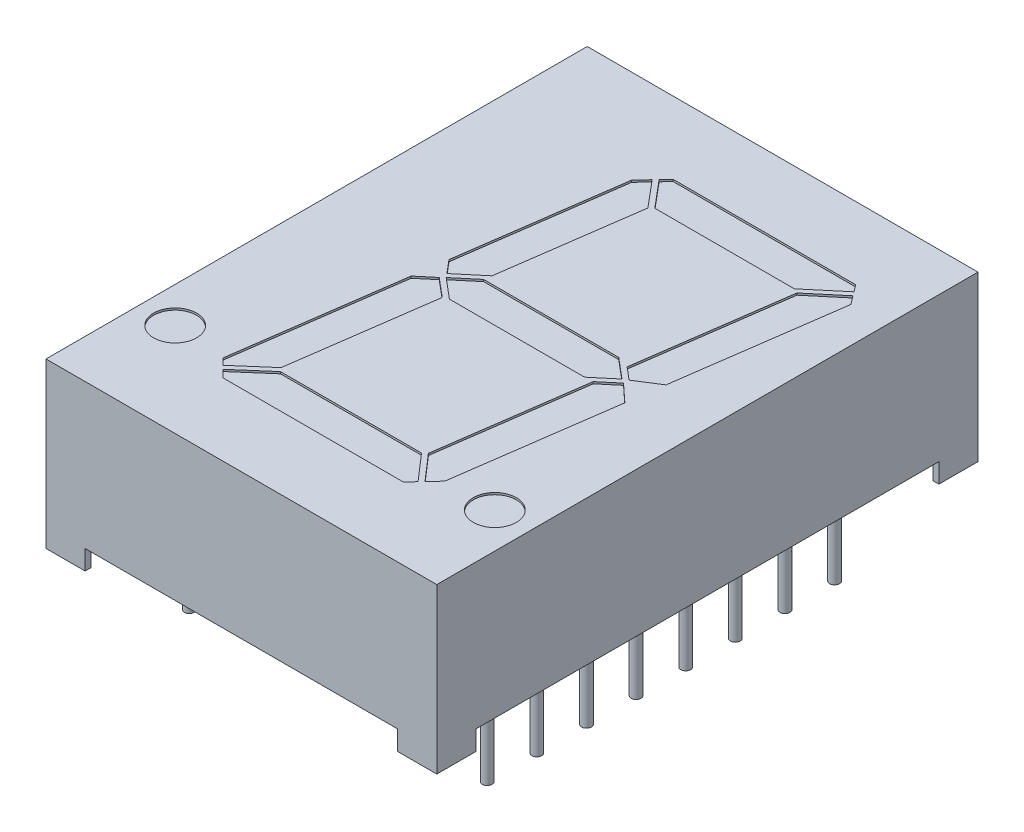
from build123d import *

# Parameters (mm, degrees)
SKETCH1_W          = 20
SKETCH1_H          = 27.7
EXTRUDE2_DEPTH     = 8.4
SKETCH2_W          = 8
SKETCH2_H          = 1
CUT_EXTRUDE2_DEPTH = 31.624336728
SKETCH3_W          = 23.7
SKETCH3_H          = 1
CUT_EXTRUDE3_DEPTH = 26.736792729
SKETCH6_R          = 1.1
CUT_EXTRUDE4_DEPTH = 0.1
SKETCH7_W          = 1.7
SKETCH7_H          = 1.7
CUT_EXTRUDE6_DEPTH = 1
SKETCH7_3_R        = 0.25
EXTRUDE3_DEPTH     = 1
SKETCH7_4_R        = 0.25
SKETCH7_4_W        = 1.7
SKETCH7_4_H        = 1.7
EXTRUDE4_DEPTH     = 4
CUT_EXTRUDE7_DEPTH = 0.01


with BuildPart() as part:
    # Sketch1 → Extrude2 (new body)
    with BuildSketch(Plane(origin=(0, 0, 0), x_dir=(1, 0, 0), z_dir=(0, 1, 0))):
        Rectangle(SKETCH1_W, SKETCH1_H)
    extrude(amount=-EXTRUDE2_DEPTH)

    # Sketch2 → Cut-Extrude2 (cut, through all)
    with BuildSketch(Plane.XY.offset(13.85)):
        with Locations((-4, -7.9)):
            Rectangle(SKETCH2_W, SKETCH2_H)
        with Locations((4, -7.9)):
            Rectangle(SKETCH2_W, SKETCH2_H)
    extrude(amount=-CUT_EXTRUDE2_DEPTH, mode=Mode.SUBTRACT)

    # Sketch3 → Cut-Extrude3 (cut, through all)
    with BuildSketch(Plane(origin=(10, 0, 0), x_dir=(0, 0, -1), z_dir=(1, 0, 0))):
        with Locations((0, -7.9)):
            Rectangle(SKETCH3_W, SKETCH3_H)
    extrude(amount=-CUT_EXTRUDE3_DEPTH, mode=Mode.SUBTRACT)

    # Sketch6 → Cut-Extrude4 (cut)
    with BuildSketch(Plane(origin=(0, 0, 0), x_dir=(-1, 0, 0), z_dir=(0, 1, 0))):
        Polygon((2.433435176, -9.60730171), (2.941033223, -9.062969448), (4.092747259, -0.868098261), (3.527367456, -0.194304848), (2.272228803, -1.247491229), (1.289013327, -8.243432859), align=None)
        Polygon((1.918035682, -10.16), (2.261655164, -9.79151322), (1.102427931, -8.41), (-6.041213399, -8.41), (-7.699102553, -9.801134178), (-7.428677759, -10.16), align=None)
        Polygon((3.550142222, 0.17519455), (4.331518452, 0.830847056), (5.518423673, 9.276116524), (5.191950187, 9.602590009), (3.602983803, 8.221322605), (2.585886741, 0.984300968), align=None)
        Polygon((-4.587215606, -0.875), (2.327215606, -0.875), (3.37, 0), (2.327215606, 0.875), (-4.587215606, 0.875), (-5.63, 0), align=None)
        Polygon((-8.180946538, -9.161705612), (-7.849762784, -9.601201299), (-6.291786749, -8.293904183), (-5.220331571, -0.67010445), (-5.860099282, -0.1332756), (-7.015053014, -0.865942131), align=None)
        Polygon((3.438969046, 8.41), (5.014741821, 9.779798375), (4.634540196, 10.16), (-4.596637953, 10.16), (-4.960572752, 9.769727709), (-3.778579488, 8.41), align=None)
        Polygon((-5.849760234, 0.141951091), (-5.006795684, 0.849282334), (-3.967256883, 8.245985243), (-5.132011502, 9.585882158), (-5.619635493, 9.062969448), (-6.755583867, 0.980276783), align=None)
        with Locations(Location((-8.180946538, 9.06, 0), (0, 0, 90))):
            Circle(SKETCH6_R)
        with Locations(Location((8.180946538, 9.06, 0), (0, 0, 90))):
            Circle(SKETCH6_R)
    extrude(amount=-CUT_EXTRUDE4_DEPTH, mode=Mode.SUBTRACT)

    # Sketch7 → Cut-Extrude6 (cut)
    with BuildSketch(Plane.XZ.offset(8.4)):
        with Locations((-8.85, 12.7)):
            Rectangle(SKETCH7_W, SKETCH7_H)
        with Locations((-8.85, -12.7)):
            Rectangle(SKETCH7_W, SKETCH7_H)
        with Locations((8.85, -12.7)):
            Rectangle(SKETCH7_W, SKETCH7_H)
        with Locations((8.85, 12.7)):
            Rectangle(SKETCH7_W, SKETCH7_H)
    extrude(amount=-CUT_EXTRUDE6_DEPTH, mode=Mode.SUBTRACT)

    # Sketch7_3 → Extrude3 (add)
    with BuildSketch(Plane.XZ.offset(8.4)):
        with Locations((-7.62, 8.89)):
            Circle(SKETCH7_3_R)
        with Locations((-7.62, 6.35)):
            Circle(SKETCH7_3_R)
        with Locations((-7.62, -8.89)):
            Circle(SKETCH7_3_R)
        with Locations((-7.62, 3.81)):
            Circle(SKETCH7_3_R)
        with Locations((-7.62, 1.27)):
            Circle(SKETCH7_3_R)
        with Locations((-7.62, -1.27)):
            Circle(SKETCH7_3_R)
        with Locations((-7.62, -3.81)):
            Circle(SKETCH7_3_R)
        with Locations((-7.62, -6.35)):
            Circle(SKETCH7_3_R)
        with Locations(Location((7.62, -6.35, 0), (0, 0, 180))):
            Circle(SKETCH7_3_R)
        with Locations(Location((7.62, -3.81, 0), (0, 0, 180))):
            Circle(SKETCH7_3_R)
        with Locations(Location((7.62, -1.27, 0), (0, 0, 180))):
            Circle(SKETCH7_3_R)
        with Locations(Location((7.62, 1.27, 0), (0, 0, 180))):
            Circle(SKETCH7_3_R)
        with Locations(Location((7.62, 3.81, 0), (0, 0, 180))):
            Circle(SKETCH7_3_R)
        with Locations(Location((7.62, -8.89, 0), (0, 0, 180))):
            Circle(SKETCH7_3_R)
        with Locations(Location((7.62, 6.35, 0), (0, 0, 180))):
            Circle(SKETCH7_3_R)
        with Locations(Location((7.62, 8.89, 0), (0, 0, 180))):
            Circle(SKETCH7_3_R)
    extrude(amount=-EXTRUDE3_DEPTH)


with BuildPart() as extrude4_tool:
    # Sketch7_4 → Extrude4 (new body)
    with BuildSketch(Plane.XZ.offset(8.4)):
        with Locations((-7.62, 8.89)):
            Circle(SKETCH7_4_R)
        with Locations((-7.62, 6.35)):
            Circle(SKETCH7_4_R)
        with Locations((-7.62, -8.89)):
            Circle(SKETCH7_4_R)
        with Locations((-7.62, 3.81)):
            Circle(SKETCH7_4_R)
        with Locations((-7.62, 1.27)):
            Circle(SKETCH7_4_R)
        with Locations((-7.62, -1.27)):
            Circle(SKETCH7_4_R)
        with Locations((-7.62, -3.81)):
            Circle(SKETCH7_4_R)
        with Locations((-7.62, -6.35)):
            Circle(SKETCH7_4_R)
        with Locations(Location((7.62, -6.35, 0), (0, 0, 180))):
            Circle(SKETCH7_4_R)
        with Locations(Location((7.62, -3.81, 0), (0, 0, 180))):
            Circle(SKETCH7_4_R)
        with Locations(Location((7.62, -1.27, 0), (0, 0, 180))):
            Circle(SKETCH7_4_R)
        with Locations(Location((7.62, 1.27, 0), (0, 0, 180))):
            Circle(SKETCH7_4_R)
        with Locations(Location((7.62, 3.81, 0), (0, 0, 180))):
            Circle(SKETCH7_4_R)
        with Locations(Location((7.62, -8.89, 0), (0, 0, 180))):
            Circle(SKETCH7_4_R)
        with Locations(Location((7.62, 6.35, 0), (0, 0, 180))):
            Circle(SKETCH7_4_R)
        with Locations(Location((7.62, 8.89, 0), (0, 0, 180))):
            Circle(SKETCH7_4_R)
        with Locations((-8.85, 12.7)):
            Rectangle(SKETCH7_4_W, SKETCH7_4_H)
        with Locations((-8.85, -12.7)):
            Rectangle(SKETCH7_4_W, SKETCH7_4_H)
        with Locations((8.85, -12.7)):
            Rectangle(SKETCH7_4_W, SKETCH7_4_H)
        with Locations((8.85, 12.7)):
            Rectangle(SKETCH7_4_W, SKETCH7_4_H)
    extrude(amount=EXTRUDE4_DEPTH)


with BuildPart() as part_1:
    add(part.part)


with BuildPart() as part_2:
    # Extrude4: joined with extrude4_tool
    add(part_1.part.fuse(extrude4_tool.part, tol=0.00001))


with BuildPart() as extrude4_kept_piece:
    # of the separate pieces the step leaves, the one the design keeps (extrude4_pieces_kept)
    add(part_2.part.solids().sort_by_distance((-10, 0, -13.85))[0])

    # Sketch8 → Cut-Extrude7 (cut)
    with BuildSketch(Plane.XZ.offset(7.4)):
        Polygon((0.650981301, 11.095437234), (0.641345884, 11.095437234), (0.619571044, 11.148001337), (0.595712871, 11.095437234), (0.594190435, 11.095437234), (0.570853096, 11.148001337), (0.548877935, 11.095437234), (0.539442839, 11.095437234), (0.569991717, 11.168514157), (0.571854698, 11.168514157), (0.59521207, 11.115950055), (0.619050211, 11.168514157), (0.620712871, 11.168514157), align=None)
        Polygon((0.535596685, 11.095437234), (0.525961269, 11.095437234), (0.504186429, 11.148001337), (0.480328256, 11.095437234), (0.47880582, 11.095437234), (0.45546848, 11.148001337), (0.43349332, 11.095437234), (0.424058224, 11.095437234), (0.454607102, 11.168514157), (0.456470083, 11.168514157), (0.479827455, 11.115950055), (0.503665596, 11.168514157), (0.505328256, 11.168514157), align=None)
        Polygon((0.42021207, 11.095437234), (0.410576653, 11.095437234), (0.388801814, 11.148001337), (0.364943641, 11.095437234), (0.363421205, 11.095437234), (0.340083865, 11.148001337), (0.318108705, 11.095437234), (0.308673609, 11.095437234), (0.339222487, 11.168514157), (0.341085467, 11.168514157), (0.364442839, 11.115950055), (0.38828098, 11.168514157), (0.389943641, 11.168514157), align=None)
        with BuildLine():
            add(Edge.make_bspline(
                [(0.28495566, 11.153129542), (0.284398411, 11.153161539), (0.283312413, 11.153223897), (0.281739855, 11.153682194), (0.28030282, 11.154455474), (0.279030697, 11.155517968), (0.2779734, 11.156786442), (0.277191223, 11.158219826), (0.276711918, 11.159796943), (0.276652672, 11.160898607), (0.276622326, 11.161462875)],
                knots=[0, 0, 0, 0, 1.020591893, 1.988988293, 2.974634352, 3.991697318, 5.008760285, 5.983632262, 6.967224335, 8, 8, 8, 8], degree=3))
            add(Edge.make_bspline(
                [(0.276622326, 11.161462875), (0.276653779, 11.16201367), (0.276715909, 11.163101704), (0.277191448, 11.164665515), (0.277972409, 11.166100527), (0.279037392, 11.167365999), (0.280295133, 11.168454064), (0.28174441, 11.169216615), (0.283308358, 11.169708497), (0.28439768, 11.169766499), (0.28495566, 11.169796209)],
                knots=[0, 0, 0, 0, 1.010056097, 1.99525427, 2.971718109, 3.990441831, 5.01702829, 6.004283803, 6.977741589, 8, 8, 8, 8], degree=3))
            add(Edge.make_bspline(
                [(0.28495566, 11.169796209), (0.285513238, 11.16976538), (0.286608179, 11.169704839), (0.28817798, 11.169226394), (0.289618477, 11.168446624), (0.290876545, 11.167367962), (0.291932968, 11.166093937), (0.292750185, 11.164675286), (0.293187783, 11.163097181), (0.293254938, 11.162012779), (0.293288993, 11.161462875)],
                knots=[0, 0, 0, 0, 1.021821805, 2.006599202, 2.982645994, 4.008793999, 5.027082625, 6.009034913, 6.990375297, 8, 8, 8, 8], degree=3))
            add(Edge.make_bspline(
                [(0.293288993, 11.161462875), (0.293255953, 11.16089953), (0.293191555, 11.159801539), (0.292750384, 11.158210065), (0.291931974, 11.156793039), (0.290883218, 11.15551602), (0.289610868, 11.154462798), (0.288182449, 11.15367255), (0.286604188, 11.153227503), (0.285512523, 11.153162633), (0.28495566, 11.153129542)],
                knots=[0, 0, 0, 0, 1.032329927, 2.012066096, 2.992413168, 4.009037178, 5.025661188, 6.000112418, 6.979848586, 8, 8, 8, 8], degree=3))
        make_face()
        with BuildLine():
            Line((0.263801814, 11.149223292), (0.255348288, 11.144155183))
            add(Edge.make_bspline(
                [(0.255348288, 11.144155183), (0.254562053, 11.145471308), (0.253055656, 11.147992954), (0.25054276, 11.151400326), (0.247938963, 11.154296388), (0.245224982, 11.156664291), (0.242417383, 11.158528545), (0.239497839, 11.159848609), (0.236476187, 11.160671922), (0.234419792, 11.160771925), (0.23339316, 11.16082185)],
                knots=[0, 0, 0, 0, 1.272034388, 2.437168799, 3.508375237, 4.49857839, 5.41946034, 6.295179144, 7.148887113, 8, 8, 8, 8], degree=3))
            add(Edge.make_bspline(
                [(0.23339316, 11.16082185), (0.23251657, 11.16079685), (0.230778728, 11.160747287), (0.228215332, 11.160290292), (0.225738213, 11.159542652), (0.223372023, 11.158529136), (0.221179343, 11.157283336), (0.21922604, 11.155814196), (0.217575635, 11.154117037), (0.216211197, 11.152253051), (0.215143093, 11.150261148), (0.214383111, 11.148190381), (0.213894915, 11.146053948), (0.213833019, 11.144605157), (0.213801814, 11.143874734)],
                knots=[0, 0, 0, 0, 1.095645842, 2.172120455, 3.244862764, 4.326153987, 5.384857088, 6.392105572, 7.372507978, 8.334705661, 9.272564127, 10.189475455, 11.087205874, 12, 12, 12, 12], degree=3))
            add(Edge.make_bspline(
                [(0.213801814, 11.143874734), (0.213843032, 11.143041861), (0.213926504, 11.141355201), (0.214662147, 11.138862475), (0.215785443, 11.136384982), (0.216841215, 11.134852204), (0.217387551, 11.134059029)],
                knots=[0, 0, 0, 0, 0.938992559, 1.901562324, 2.914110574, 4, 4, 4, 4], degree=3))
            add(Edge.make_bspline(
                [(0.217387551, 11.134059029), (0.217833949, 11.133485019), (0.218773858, 11.13227642), (0.220413494, 11.130508971), (0.222277864, 11.128637569), (0.224415236, 11.126699567), (0.226794444, 11.12465532), (0.22944246, 11.122542743), (0.232328366, 11.120330327), (0.234363879, 11.11886909), (0.235416397, 11.118113516)],
                knots=[0, 0, 0, 0, 0.722283655, 1.520795216, 2.39349503, 3.346893347, 4.386874146, 5.510198126, 6.712579003, 8, 8, 8, 8], degree=3))
            add(Edge.make_bspline(
                [(0.235416397, 11.118113516), (0.236468371, 11.117363957), (0.238479665, 11.115930856), (0.241294581, 11.113806665), (0.243808362, 11.111852175), (0.246033814, 11.110094611), (0.247913365, 11.108457316), (0.249515723, 11.107028042), (0.250781773, 11.105730465), (0.2514863, 11.10488938), (0.251802615, 11.104511754)],
                knots=[0, 0, 0, 0, 1.452255772, 2.776602448, 3.96446981, 5.032613149, 5.964194703, 6.766668629, 7.446264616, 8, 8, 8, 8], degree=3))
            add(Edge.make_bspline(
                [(0.251802615, 11.104511754), (0.252244614, 11.103923123), (0.253113863, 11.102765503), (0.254262519, 11.100956638), (0.255231184, 11.099108492), (0.256010778, 11.097214369), (0.256641206, 11.095288503), (0.257079515, 11.093316435), (0.25734968, 11.091311554), (0.257377587, 11.089962644), (0.257391557, 11.089287395)],
                knots=[0, 0, 0, 0, 1.068019517, 2.100403715, 3.106014851, 4.09224787, 5.069873182, 6.043214339, 7.020455327, 8, 8, 8, 8], degree=3))
            add(Edge.make_bspline(
                [(0.257391557, 11.089287395), (0.25735443, 11.08822931), (0.257280969, 11.086135758), (0.25665457, 11.083079049), (0.255677556, 11.080151662), (0.254264041, 11.07741875), (0.252518086, 11.074884187), (0.250445634, 11.072592933), (0.248007873, 11.070623856), (0.245294023, 11.068949984), (0.242358197, 11.067614607), (0.239272816, 11.066641568), (0.236051743, 11.066071308), (0.233862811, 11.06599087), (0.232752134, 11.065950055)],
                knots=[0, 0, 0, 0, 1.005367131, 1.989245246, 2.955191616, 3.932180104, 4.904534562, 5.875498653, 6.859376768, 7.874484044, 8.900379497, 9.918679785, 10.943926428, 12, 12, 12, 12], degree=3))
            add(Edge.make_bspline(
                [(0.232752134, 11.065950055), (0.231573367, 11.065989389), (0.229235731, 11.066067394), (0.225796173, 11.066787337), (0.222464806, 11.06790594), (0.219794977, 11.069238175), (0.217704674, 11.070554422), (0.216112269, 11.071756352), (0.214489799, 11.073137078), (0.212854745, 11.07472585), (0.211190951, 11.076490849), (0.209506086, 11.078447029), (0.207784382, 11.080576757), (0.206677134, 11.082097522), (0.206109506, 11.082877138)],
                knots=[0, 0, 0, 0, 1.286534051, 2.551350862, 3.822568981, 5.117864672, 5.799956111, 6.519305446, 7.295594771, 8.126302591, 9.008831062, 9.944975596, 10.946496709, 12, 12, 12, 12], degree=3))
            Line((0.206109506, 11.082877138), (0.214222487, 11.089026978))
            add(Edge.make_bspline(
                [(0.214222487, 11.089026978), (0.214712335, 11.088395836), (0.215655668, 11.087180404), (0.217088414, 11.085478853), (0.218436765, 11.083922449), (0.219775384, 11.08257415), (0.221001086, 11.081332974), (0.222211843, 11.080289222), (0.223360882, 11.079409756), (0.224805926, 11.078469972), (0.226641137, 11.077560724), (0.228923394, 11.076778987), (0.231309992, 11.076298563), (0.232930201, 11.076237502), (0.233753737, 11.076206465)],
                knots=[0, 0, 0, 0, 1.181426797, 2.275151783, 3.28963443, 4.225459815, 5.084396437, 5.868484344, 6.587427557, 7.222918358, 8.415355282, 9.605213164, 10.782753814, 12, 12, 12, 12], degree=3))
            add(Edge.make_bspline(
                [(0.233753737, 11.076206465), (0.234787024, 11.076240518), (0.236779621, 11.076306186), (0.239601935, 11.077042254), (0.242156834, 11.078161396), (0.244346784, 11.079775186), (0.246154992, 11.081699135), (0.247479212, 11.083893264), (0.248270939, 11.086316593), (0.248367846, 11.088006221), (0.248417198, 11.088866722)],
                knots=[0, 0, 0, 0, 1.144248881, 2.206576175, 3.214949548, 4.222996039, 5.203671638, 6.127710127, 7.046472867, 8, 8, 8, 8], degree=3))
            add(Edge.make_bspline(
                [(0.248417198, 11.088866722), (0.248404794, 11.089402214), (0.248379812, 11.09048066), (0.248081965, 11.092070714), (0.247637491, 11.09364205), (0.247007461, 11.09520372), (0.246151243, 11.096800215), (0.244988349, 11.098422436), (0.243533142, 11.100110982), (0.242416308, 11.101208132), (0.241826653, 11.101787395)],
                knots=[0, 0, 0, 0, 0.858500039, 1.728959331, 2.587258638, 3.476905708, 4.426389682, 5.487945037, 6.673710648, 8, 8, 8, 8], degree=3))
            add(Edge.make_bspline(
                [(0.241826653, 11.101787395), (0.241607757, 11.101982738), (0.241087709, 11.10244683), (0.240136969, 11.103206609), (0.23888146, 11.104143831), (0.237353969, 11.105303469), (0.23552633, 11.106648654), (0.233398342, 11.108162185), (0.230993727, 11.109893199), (0.229287387, 11.111103414), (0.228385147, 11.111743324)],
                knots=[0, 0, 0, 0, 0.420754252, 0.999615792, 1.744751191, 2.668019286, 3.750313428, 4.999500688, 6.413464383, 8, 8, 8, 8], degree=3))
            add(Edge.make_bspline(
                [(0.228385147, 11.111743324), (0.227299836, 11.112533078), (0.225198282, 11.114062326), (0.222208055, 11.11635991), (0.219496838, 11.118607015), (0.217054913, 11.120789145), (0.214858827, 11.122890237), (0.212930717, 11.124933939), (0.211261835, 11.126906849), (0.209440628, 11.129419042), (0.207601749, 11.132532997), (0.206025061, 11.136349899), (0.205021999, 11.140177755), (0.204891729, 11.142747209), (0.204827455, 11.144014959)],
                knots=[0, 0, 0, 0, 1.163604038, 2.253157948, 3.268574773, 4.215621239, 5.091738613, 5.902582348, 6.650434646, 7.330118262, 8.591011492, 9.77460283, 10.902005569, 12, 12, 12, 12], degree=3))
            add(Edge.make_bspline(
                [(0.204827455, 11.144014959), (0.20484626, 11.144911467), (0.204883504, 11.146687074), (0.205310529, 11.149294602), (0.205938405, 11.151826017), (0.206874178, 11.154249815), (0.208043921, 11.156593009), (0.209468074, 11.158851492), (0.211193986, 11.160988154), (0.213111267, 11.16304449), (0.21524088, 11.164904242), (0.217494447, 11.166560694), (0.219859316, 11.167978985), (0.222362496, 11.169093226), (0.224962752, 11.169984523), (0.22767229, 11.170623382), (0.230496931, 11.171016812), (0.232416973, 11.171057549), (0.23339316, 11.17107826)],
                knots=[0, 0, 0, 0, 0.98378539, 1.948466333, 2.894822735, 3.844243623, 4.795447569, 5.768042124, 6.770299647, 7.807997672, 8.852593179, 9.870666288, 10.876941106, 11.874841786, 12.874492863, 13.892063892, 14.928283473, 16, 16, 16, 16], degree=3))
            add(Edge.make_bspline(
                [(0.23339316, 11.17107826), (0.234148422, 11.171063487), (0.235649435, 11.171034128), (0.237863655, 11.170780725), (0.240037215, 11.170409105), (0.242142824, 11.16984252), (0.244206698, 11.169138909), (0.24621045, 11.168277447), (0.248158913, 11.167251895), (0.250054495, 11.166060668), (0.251914544, 11.164687462), (0.253731555, 11.163101952), (0.255514623, 11.161311726), (0.257271155, 11.159319276), (0.258959773, 11.157091667), (0.260622941, 11.154664228), (0.262251999, 11.152029115), (0.26327556, 11.150176035), (0.263801814, 11.149223292)],
                knots=[0, 0, 0, 0, 0.915366252, 1.81920441, 2.69897508, 3.586533125, 4.459536084, 5.340758185, 6.227946952, 7.126403341, 8.052553006, 9.028121456, 10.047063623, 11.114014537, 12.24582441, 13.433687931, 14.680555077, 16, 16, 16, 16], degree=3))
        make_face()
        with BuildLine():
            Line((0.188160788, 11.095437234), (0.179186429, 11.095437234))
            Line((0.179186429, 11.095437234), (0.179186429, 11.129331465))
            add(Edge.make_bspline(
                [(0.179186429, 11.129331465), (0.179182375, 11.130326401), (0.179174619, 11.132229666), (0.17912202, 11.134968386), (0.178998303, 11.137466006), (0.178843623, 11.13972397), (0.178644705, 11.141741896), (0.178408037, 11.143512734), (0.178143511, 11.145056568), (0.177884576, 11.145986378), (0.177764153, 11.146418805)],
                knots=[0, 0, 0, 0, 1.388932606, 2.656963016, 3.823490214, 4.879454478, 5.816252168, 6.653371382, 7.373723809, 8, 8, 8, 8], degree=3))
            add(Edge.make_bspline(
                [(0.177764153, 11.146418805), (0.177570968, 11.146962314), (0.177188613, 11.148038033), (0.176495103, 11.149592026), (0.175637082, 11.151031238), (0.174698484, 11.152411658), (0.173614682, 11.153690567), (0.172401524, 11.154876316), (0.171080542, 11.155982738), (0.169145565, 11.157317172), (0.166500427, 11.158729373), (0.16303538, 11.159964873), (0.15927145, 11.160692398), (0.156666947, 11.160777902), (0.155328256, 11.16082185)],
                knots=[0, 0, 0, 0, 0.725930277, 1.436768641, 2.137297926, 2.832005607, 3.535753883, 4.242956221, 4.964984144, 5.701683124, 7.198126434, 8.723945959, 10.316137162, 12, 12, 12, 12], degree=3))
            add(Edge.make_bspline(
                [(0.155328256, 11.16082185), (0.153989395, 11.160778066), (0.15140551, 11.160693567), (0.147680909, 11.159975857), (0.144269905, 11.158804972), (0.141212327, 11.157147629), (0.138527367, 11.155127112), (0.136290154, 11.152755257), (0.134444218, 11.150108177), (0.133638237, 11.148133191), (0.133232903, 11.147139959)],
                knots=[0, 0, 0, 0, 1.157091467, 2.233085092, 3.266839029, 4.264239195, 5.228693433, 6.160074799, 7.074690074, 8, 8, 8, 8], degree=3))
            add(Edge.make_bspline(
                [(0.133232903, 11.147139959), (0.13311298, 11.14674093), (0.132847857, 11.145858775), (0.132565043, 11.144362037), (0.132299734, 11.142578857), (0.132122855, 11.140490511), (0.131920982, 11.138115414), (0.131851275, 11.135441282), (0.131751729, 11.13248388), (0.131750942, 11.130413321), (0.131750532, 11.129331465)],
                knots=[0, 0, 0, 0, 0.557560243, 1.232629526, 2.036798082, 2.970922211, 4.03790722, 5.227863888, 6.551574656, 8, 8, 8, 8], degree=3))
            Line((0.131750532, 11.129331465), (0.131750532, 11.095437234))
            Line((0.131750532, 11.095437234), (0.122776173, 11.095437234))
            Line((0.122776173, 11.095437234), (0.122776173, 11.131014157))
            add(Edge.make_bspline(
                [(0.122776173, 11.131014157), (0.122788838, 11.132222927), (0.12281341, 11.134568105), (0.122970146, 11.137976314), (0.123242819, 11.141158659), (0.123646007, 11.144105397), (0.12413513, 11.146817233), (0.12475363, 11.149295022), (0.125496073, 11.151542208), (0.126333844, 11.15359158), (0.127321116, 11.155451478), (0.128378342, 11.157206854), (0.129567089, 11.158851922), (0.130863589, 11.160401733), (0.132305368, 11.161818676), (0.133817133, 11.163175403), (0.135472709, 11.164388213), (0.137216302, 11.16552171), (0.13909187, 11.166527611), (0.141083279, 11.167397989), (0.143188425, 11.1681542), (0.145410594, 11.168738561), (0.147748483, 11.169231566), (0.150199108, 11.169559702), (0.152767132, 11.169769213), (0.154513183, 11.169787059), (0.155408384, 11.169796209)],
                knots=[0, 0, 0, 0, 1.493120159, 2.896857355, 4.213387119, 5.437035652, 6.569467867, 7.615715674, 8.588612823, 9.490833737, 10.346735778, 11.186995163, 12.020221603, 12.851363391, 13.679553205, 14.515225522, 15.358192885, 16.211587453, 17.082499898, 17.983626775, 18.894104459, 19.842498226, 20.819547185, 21.843713668, 22.894470975, 24, 24, 24, 24], degree=3))
            add(Edge.make_bspline(
                [(0.155408384, 11.169796209), (0.156296861, 11.169786516), (0.1580428, 11.16976747), (0.160604768, 11.169563226), (0.163060683, 11.169226539), (0.165400413, 11.168742513), (0.167633389, 11.16814949), (0.169748769, 11.167403305), (0.171749226, 11.16652263), (0.173639063, 11.16552077), (0.17541201, 11.164392338), (0.177064083, 11.163150373), (0.178624733, 11.161827278), (0.180050639, 11.16037793), (0.18135226, 11.158813179), (0.182535238, 11.157140058), (0.183619807, 11.155377477), (0.18460129, 11.153489928), (0.185444491, 11.151416451), (0.186188924, 11.149122245), (0.1867978, 11.146582174), (0.187293299, 11.143798405), (0.187691912, 11.140784261), (0.187968659, 11.137522306), (0.188123397, 11.134020486), (0.188148055, 11.131601918), (0.188160788, 11.1303531)],
                knots=[0, 0, 0, 0, 1.083759936, 2.129689164, 3.133164553, 4.10615121, 5.04285688, 5.949793092, 6.839814394, 7.707177441, 8.556916231, 9.400895077, 10.227072161, 11.05083587, 11.877976332, 12.707560346, 13.548664154, 14.401248865, 15.299878211, 16.27626931, 17.341250723, 18.483766318, 19.724630785, 21.049282549, 22.476408703, 24, 24, 24, 24], degree=3))
            Line((0.188160788, 11.1303531), (0.188160788, 11.095437234))
        make_face()
        with BuildLine():
            Line((0.102263352, 11.095437234), (0.093288993, 11.095437234))
            Line((0.093288993, 11.095437234), (0.093288993, 11.108618324))
            add(Edge.make_bspline(
                [(0.093288993, 11.108618324), (0.092332429, 11.10742103), (0.090479099, 11.105101289), (0.087360909, 11.102076369), (0.084109565, 11.099537977), (0.08067226, 11.097539359), (0.077084363, 11.096027799), (0.073356057, 11.094937786), (0.069467161, 11.094283815), (0.06682245, 11.094198396), (0.065484506, 11.094155183)],
                knots=[0, 0, 0, 0, 1.127869841, 2.185233117, 3.191641716, 4.159226741, 5.10472073, 6.052603964, 7.014823782, 8, 8, 8, 8], degree=3))
            add(Edge.make_bspline(
                [(0.065484506, 11.094155183), (0.064131557, 11.094202229), (0.061482181, 11.094294355), (0.057638589, 11.095106108), (0.05402366, 11.096390713), (0.050685731, 11.098196161), (0.047676165, 11.100437741), (0.045066357, 11.103067132), (0.042871642, 11.106052655), (0.041406771, 11.108847175), (0.040459308, 11.111329424), (0.039836673, 11.113452557), (0.039332948, 11.115818945), (0.03888159, 11.118422736), (0.038580485, 11.121274388), (0.038341804, 11.124367097), (0.038171081, 11.127700325), (0.03816429, 11.130005653), (0.038160788, 11.131194446)],
                knots=[0, 0, 0, 0, 1.235764162, 2.419900973, 3.574701258, 4.732869372, 5.875730734, 6.993815468, 8.107424371, 9.251605764, 9.866123335, 10.534503958, 11.272175692, 12.077112099, 12.949509943, 13.89253218, 14.913238789, 16, 16, 16, 16], degree=3))
            Line((0.038160788, 11.131194446), (0.038160788, 11.168514157))
            Line((0.038160788, 11.168514157), (0.047135147, 11.168514157))
            Line((0.047135147, 11.168514157), (0.047135147, 11.134139157))
            add(Edge.make_bspline(
                [(0.047135147, 11.134139157), (0.047140644, 11.133144229), (0.04715116, 11.1312411), (0.047184761, 11.12851629), (0.047263855, 11.126051848), (0.047379567, 11.123840693), (0.047541534, 11.121890918), (0.047714922, 11.120192654), (0.047925217, 11.118760942), (0.048112743, 11.117899084), (0.048196846, 11.117512555)],
                knots=[0, 0, 0, 0, 1.430803381, 2.736883362, 3.918614142, 4.976458302, 5.92063272, 6.731858525, 7.431260095, 8, 8, 8, 8], degree=3))
            add(Edge.make_bspline(
                [(0.048196846, 11.117512555), (0.048498925, 11.116377134), (0.049078789, 11.114197613), (0.050540789, 11.111246318), (0.052344151, 11.10871328), (0.054578476, 11.106650597), (0.057183753, 11.10504485), (0.060164316, 11.103931554), (0.063489316, 11.103235018), (0.065828028, 11.103165681), (0.067047006, 11.103129542)],
                knots=[0, 0, 0, 0, 1.084232, 2.08126119, 3.027460722, 3.945137793, 4.874029258, 5.839697328, 6.874011781, 8, 8, 8, 8], degree=3))
            add(Edge.make_bspline(
                [(0.067047006, 11.103129542), (0.067769006, 11.103142941), (0.069197827, 11.103169458), (0.071315425, 11.103442423), (0.07337597, 11.103873536), (0.075373943, 11.104510319), (0.077313381, 11.105284558), (0.07920231, 11.106234586), (0.081014335, 11.107383726), (0.082774938, 11.10867536), (0.084411344, 11.110113757), (0.085955693, 11.11160959), (0.087312594, 11.113225493), (0.088544281, 11.114904333), (0.089606213, 11.116679834), (0.090533525, 11.118533018), (0.091320238, 11.120466816), (0.091711175, 11.121808958), (0.091906782, 11.122480504)],
                knots=[0, 0, 0, 0, 1.023939463, 2.026349741, 3.024227553, 4.007104963, 4.997624259, 5.984875705, 7.002218968, 8.038748769, 9.079772093, 10.091408226, 11.086177727, 12.069739863, 13.043026652, 14.017557731, 15.008077027, 16, 16, 16, 16], degree=3))
            add(Edge.make_bspline(
                [(0.091906782, 11.122480504), (0.092019343, 11.122973509), (0.092264383, 11.124046757), (0.092529046, 11.125808026), (0.092769262, 11.127845454), (0.092970318, 11.130156663), (0.09309333, 11.132749745), (0.093227455, 11.135613627), (0.093276286, 11.138759726), (0.093284639, 11.14095006), (0.093288993, 11.142091882)],
                knots=[0, 0, 0, 0, 0.615963638, 1.340920617, 2.168419149, 3.115676021, 4.16674242, 5.331190069, 6.6087489, 8, 8, 8, 8], degree=3))
            Line((0.093288993, 11.142091882), (0.093288993, 11.168514157))
            Line((0.093288993, 11.168514157), (0.102263352, 11.168514157))
            Line((0.102263352, 11.168514157), (0.102263352, 11.095437234))
        make_face()
        Polygon((0.015083865, 11.068514157), (0.006109506, 11.068514157), (0.006109506, 11.158257747), (-0.032352033, 11.158257747), (-0.032352033, 11.168514157), (0.015083865, 11.168514157), align=None)
        Polygon((-0.049018699, 11.068514157), (-0.105428956, 11.068514157), (-0.105428956, 11.078770568), (-0.057993058, 11.078770568), (-0.057993058, 11.109539798), (-0.105428956, 11.109539798), (-0.105428956, 11.119796209), (-0.057993058, 11.119796209), (-0.057993058, 11.158257747), (-0.105428956, 11.158257747), (-0.105428956, 11.168514157), (-0.049018699, 11.168514157), align=None)
        with BuildLine():
            Line((-0.123377674, 11.168514157), (-0.123377674, 11.068514157))
            Line((-0.123377674, 11.068514157), (-0.143569981, 11.068514157))
            add(Edge.make_bspline(
                [(-0.143569981, 11.068514157), (-0.145326242, 11.068526768), (-0.148719328, 11.068551131), (-0.153622492, 11.06870649), (-0.1581527, 11.068978544), (-0.16230738, 11.069382467), (-0.166093207, 11.069867288), (-0.169504117, 11.070483859), (-0.172545638, 11.071208989), (-0.174416189, 11.07182746), (-0.17530075, 11.072119927)],
                knots=[0, 0, 0, 0, 1.314317071, 2.539253741, 3.67075822, 4.709970291, 5.662644612, 6.526156501, 7.303037452, 8, 8, 8, 8], degree=3))
            add(Edge.make_bspline(
                [(-0.17530075, 11.072119927), (-0.176457846, 11.072560667), (-0.178745799, 11.073432154), (-0.182001644, 11.075078605), (-0.185077052, 11.076936479), (-0.187947742, 11.07904837), (-0.190620037, 11.08138729), (-0.193127562, 11.083934316), (-0.195398443, 11.086757444), (-0.197511004, 11.089769075), (-0.199360042, 11.092996613), (-0.200990538, 11.096375413), (-0.202382735, 11.099898919), (-0.203469022, 11.103592839), (-0.204366483, 11.107421695), (-0.204968657, 11.111414477), (-0.205368657, 11.115547906), (-0.205408659, 11.118352927), (-0.205428956, 11.119776177)],
                knots=[0, 0, 0, 0, 0.984696416, 1.947063185, 2.89840987, 3.841051395, 4.778753227, 5.721858861, 6.681155121, 7.65838316, 8.646299769, 9.637283673, 10.641736726, 11.657050558, 12.698485921, 13.768600492, 14.86780186, 16, 16, 16, 16], degree=3))
            add(Edge.make_bspline(
                [(-0.205428956, 11.119776177), (-0.205410973, 11.121012208), (-0.205375536, 11.123447936), (-0.205057729, 11.127037736), (-0.204594915, 11.130520762), (-0.203881666, 11.13388172), (-0.203005242, 11.137143238), (-0.201923512, 11.140289875), (-0.200641387, 11.143323767), (-0.199154487, 11.146220819), (-0.197526391, 11.148973985), (-0.195752314, 11.151539643), (-0.193892998, 11.153946082), (-0.19188063, 11.156138936), (-0.18978184, 11.158186491), (-0.187525242, 11.159997919), (-0.185181495, 11.161657315), (-0.182680185, 11.163114284), (-0.18000079, 11.164410301), (-0.17707332, 11.165504796), (-0.17390846, 11.16644669), (-0.170485239, 11.167197127), (-0.166815073, 11.167802017), (-0.162888014, 11.168204843), (-0.158711415, 11.168478009), (-0.155843426, 11.168501874), (-0.154367257, 11.168514157)],
                knots=[0, 0, 0, 0, 1.105894396, 2.179280415, 3.222964075, 4.248423888, 5.251546139, 6.243661943, 7.223682738, 8.196462441, 9.155694589, 10.083899862, 10.986397372, 11.874737962, 12.745335529, 13.607670254, 14.461432187, 15.313100333, 16.195087267, 17.121790994, 18.106827133, 19.14775296, 20.255889161, 21.433815148, 22.679170477, 24, 24, 24, 24], degree=3))
            Line((-0.154367257, 11.168514157), (-0.123377674, 11.168514157))
        make_face()
        with BuildLine():
            Line((-0.132352033, 11.158257747), (-0.143830398, 11.158257747))
            add(Edge.make_bspline(
                [(-0.143830398, 11.158257747), (-0.14547978, 11.158250659), (-0.148652146, 11.158237025), (-0.153213803, 11.158117391), (-0.157381785, 11.157921907), (-0.161156686, 11.157648333), (-0.164536372, 11.157286373), (-0.167527908, 11.156882804), (-0.170121487, 11.15638002), (-0.171690899, 11.155924278), (-0.172416135, 11.155713677)],
                knots=[0, 0, 0, 0, 1.375205317, 2.645023457, 3.804390687, 4.853969522, 5.800190428, 6.637939096, 7.370582563, 8, 8, 8, 8], degree=3))
            add(Edge.make_bspline(
                [(-0.172416135, 11.155713677), (-0.173328965, 11.155392228), (-0.175132821, 11.154757007), (-0.177729143, 11.15359787), (-0.180151807, 11.15222652), (-0.1824412, 11.150693161), (-0.18458261, 11.148974113), (-0.18656612, 11.147063912), (-0.188407398, 11.144984671), (-0.190076962, 11.142729384), (-0.19158695, 11.140323075), (-0.192891575, 11.137768425), (-0.193991359, 11.135079769), (-0.194893658, 11.132266461), (-0.195597143, 11.129326828), (-0.196092423, 11.126253491), (-0.196399343, 11.123047665), (-0.196435978, 11.120865281), (-0.196454597, 11.119756145)],
                knots=[0, 0, 0, 0, 0.998420628, 1.972994, 2.929372424, 3.86770908, 4.81360496, 5.759023883, 6.706048443, 7.676227424, 8.651287839, 9.634325482, 10.632389399, 11.645655052, 12.680158286, 13.74837235, 14.855672678, 16, 16, 16, 16], degree=3))
            add(Edge.make_bspline(
                [(-0.196454597, 11.119756145), (-0.196439916, 11.118586624), (-0.196411075, 11.116289089), (-0.196049173, 11.112917827), (-0.195519183, 11.109675883), (-0.194756833, 11.106560921), (-0.193771944, 11.103576996), (-0.192593443, 11.100707249), (-0.191162558, 11.09798861), (-0.189542645, 11.095398055), (-0.187723997, 11.092974816), (-0.185714679, 11.090747281), (-0.183535881, 11.088711302), (-0.181197642, 11.086863637), (-0.17866727, 11.085237144), (-0.175987585, 11.083790241), (-0.173120839, 11.082560867), (-0.171126153, 11.081907233), (-0.170112449, 11.081575055)],
                knots=[0, 0, 0, 0, 1.122272916, 2.204715076, 3.251197285, 4.274229216, 5.279697671, 6.265416158, 7.248880903, 8.225321784, 9.195852973, 10.153576302, 11.101466393, 12.055578741, 13.010401466, 13.985536859, 14.976245305, 16, 16, 16, 16], degree=3))
            add(Edge.make_bspline(
                [(-0.170112449, 11.081575055), (-0.169273845, 11.081343157), (-0.167490742, 11.080850078), (-0.164581043, 11.080312211), (-0.161306325, 11.079837796), (-0.157652048, 11.079436138), (-0.153622377, 11.079147929), (-0.149214215, 11.078931606), (-0.144425655, 11.078785702), (-0.141106154, 11.078775739), (-0.139383283, 11.078770568)],
                knots=[0, 0, 0, 0, 0.674548936, 1.434276114, 2.292660221, 3.240891867, 4.284742987, 5.42552168, 6.663806718, 8, 8, 8, 8], degree=3))
            Line((-0.139383283, 11.078770568), (-0.132352033, 11.078770568))
            Line((-0.132352033, 11.078770568), (-0.132352033, 11.158257747))
        make_face(mode=Mode.SUBTRACT)
        with BuildLine():
            add(Edge.make_bspline(
                [(-0.232993058, 11.153129542), (-0.233550307, 11.153161539), (-0.234636305, 11.153223897), (-0.236208863, 11.153682194), (-0.237645898, 11.154455474), (-0.23891802, 11.155517968), (-0.239975317, 11.156786442), (-0.240757495, 11.158219826), (-0.2412368, 11.159796943), (-0.241296046, 11.160898607), (-0.241326391, 11.161462875)],
                knots=[0, 0, 0, 0, 1.020591893, 1.988988293, 2.974634352, 3.991697318, 5.008760285, 5.983632262, 6.967224335, 8, 8, 8, 8], degree=3))
            add(Edge.make_bspline(
                [(-0.241326391, 11.161462875), (-0.241294939, 11.16201367), (-0.241232809, 11.163101704), (-0.24075727, 11.164665515), (-0.239976309, 11.166100527), (-0.238911326, 11.167365999), (-0.237653584, 11.168454064), (-0.236204308, 11.169216615), (-0.234640359, 11.169708497), (-0.233551038, 11.169766499), (-0.232993058, 11.169796209)],
                knots=[0, 0, 0, 0, 1.010056097, 1.99525427, 2.971718109, 3.990441831, 5.01702829, 6.004283803, 6.977741589, 8, 8, 8, 8], degree=3))
            add(Edge.make_bspline(
                [(-0.232993058, 11.169796209), (-0.23243548, 11.16976538), (-0.231340539, 11.169704839), (-0.229770738, 11.169226394), (-0.228330241, 11.168446624), (-0.227072173, 11.167367962), (-0.22601575, 11.166093937), (-0.225198533, 11.164675286), (-0.224760935, 11.163097181), (-0.22469378, 11.162012779), (-0.224659725, 11.161462875)],
                knots=[0, 0, 0, 0, 1.021821805, 2.006599202, 2.982645994, 4.008793999, 5.027082625, 6.009034913, 6.990375297, 8, 8, 8, 8], degree=3))
            add(Edge.make_bspline(
                [(-0.224659725, 11.161462875), (-0.224692765, 11.16089953), (-0.224757163, 11.159801539), (-0.225198334, 11.158210065), (-0.226016744, 11.156793039), (-0.2270655, 11.15551602), (-0.22833785, 11.154462798), (-0.229766269, 11.15367255), (-0.23134453, 11.153227503), (-0.232436195, 11.153162633), (-0.232993058, 11.153129542)],
                knots=[0, 0, 0, 0, 1.032329927, 2.012066096, 2.992413168, 4.009037178, 5.025661188, 6.000112418, 6.979848586, 8, 8, 8, 8], degree=3))
        make_face()
        with BuildLine():
            Line((-0.333634084, 11.111282587), (-0.326122065, 11.115950055))
            add(Edge.make_bspline(
                [(-0.326122065, 11.115950055), (-0.3252984, 11.1149263), (-0.323677156, 11.112911212), (-0.320861093, 11.110312166), (-0.317858496, 11.108070792), (-0.314612751, 11.106268632), (-0.311152296, 11.104846012), (-0.307470003, 11.10385731), (-0.303567006, 11.103235855), (-0.300890775, 11.10316556), (-0.2995195, 11.103129542)],
                knots=[0, 0, 0, 0, 1.026629843, 2.020746545, 2.988156479, 3.951609825, 4.916760838, 5.907688704, 6.927920211, 8, 8, 8, 8], degree=3))
            add(Edge.make_bspline(
                [(-0.2995195, 11.103129542), (-0.298423532, 11.103159739), (-0.296265051, 11.103219212), (-0.293096285, 11.103590915), (-0.290077999, 11.104266495), (-0.28719088, 11.105156181), (-0.284456896, 11.106350297), (-0.281868386, 11.107794679), (-0.279416693, 11.109495482), (-0.277140765, 11.111440453), (-0.275066598, 11.113576734), (-0.273232171, 11.115832739), (-0.271701098, 11.118224261), (-0.270424826, 11.120705912), (-0.269464582, 11.123320384), (-0.268758443, 11.126035916), (-0.268328022, 11.128870376), (-0.26827587, 11.130798999), (-0.268249468, 11.131775375)],
                knots=[0, 0, 0, 0, 1.11253269, 2.191102883, 3.232049486, 4.248096668, 5.252846381, 6.25411548, 7.252444123, 8.276484619, 9.287796331, 10.271127345, 11.222403915, 12.165070373, 13.097940083, 14.043161362, 15.009338842, 16, 16, 16, 16], degree=3))
            add(Edge.make_bspline(
                [(-0.268249468, 11.131775375), (-0.26830096, 11.133054369), (-0.268403512, 11.135601668), (-0.269186949, 11.139354429), (-0.270489484, 11.142982912), (-0.272283711, 11.14644477), (-0.274524304, 11.149658495), (-0.277137595, 11.152564662), (-0.280182906, 11.155041831), (-0.283570502, 11.157115052), (-0.287239311, 11.158788409), (-0.291160223, 11.159969197), (-0.295299857, 11.160685898), (-0.298134385, 11.160775941), (-0.299579597, 11.16082185)],
                knots=[0, 0, 0, 0, 0.966432114, 1.924787868, 2.884432441, 3.8733594, 4.863432433, 5.839037063, 6.818291847, 7.820033371, 8.83442759, 9.858062464, 10.907912868, 12, 12, 12, 12], degree=3))
            add(Edge.make_bspline(
                [(-0.299579597, 11.16082185), (-0.30090403, 11.160784721), (-0.303506894, 11.160711754), (-0.307311674, 11.160096641), (-0.310933957, 11.15908968), (-0.314373615, 11.157685461), (-0.317624363, 11.155870389), (-0.320665196, 11.153631556), (-0.323556623, 11.151033367), (-0.325256537, 11.149024282), (-0.326122065, 11.148001337)],
                knots=[0, 0, 0, 0, 1.039848629, 2.043578496, 3.018386758, 3.987534228, 4.954977003, 5.934852016, 6.948509513, 8, 8, 8, 8], degree=3))
            Line((-0.326122065, 11.148001337), (-0.333634084, 11.152929222))
            add(Edge.make_bspline(
                [(-0.333634084, 11.152929222), (-0.333188717, 11.153583237), (-0.332299462, 11.154889097), (-0.330813015, 11.156730437), (-0.329209377, 11.158453614), (-0.327496084, 11.160058112), (-0.325694881, 11.161572076), (-0.323758881, 11.162952602), (-0.321721044, 11.164234623), (-0.31957202, 11.16539642), (-0.317332974, 11.166438453), (-0.315003838, 11.167340234), (-0.312595132, 11.168102689), (-0.310112269, 11.168719638), (-0.307551332, 11.169207718), (-0.30491427, 11.169532331), (-0.302201577, 11.169774422), (-0.300368089, 11.169788884), (-0.299439372, 11.169796209)],
                knots=[0, 0, 0, 0, 0.954067324, 1.904967979, 2.850944488, 3.791040077, 4.734579251, 5.686741025, 6.656553487, 7.63677735, 8.631289747, 9.633371755, 10.647134148, 11.676547777, 12.717490898, 13.789379914, 14.88025357, 16, 16, 16, 16], degree=3))
            add(Edge.make_bspline(
                [(-0.299439372, 11.169796209), (-0.298021937, 11.169770701), (-0.295243754, 11.169720707), (-0.291177135, 11.16917249), (-0.28729198, 11.168342962), (-0.283581461, 11.167162462), (-0.280068268, 11.165603475), (-0.27672313, 11.163742776), (-0.273580656, 11.161518835), (-0.270661111, 11.158984641), (-0.267992152, 11.156233711), (-0.26566631, 11.153284074), (-0.26370592, 11.150190705), (-0.262047737, 11.146966405), (-0.260817218, 11.143568738), (-0.259934642, 11.140030927), (-0.259374073, 11.136353846), (-0.259308402, 11.133847371), (-0.259275109, 11.132576657)],
                knots=[0, 0, 0, 0, 1.113059169, 2.18160405, 3.217886321, 4.231664885, 5.234757072, 6.233049254, 7.234521092, 8.253729116, 9.266692789, 10.241774134, 11.199466202, 12.140354715, 13.084805663, 14.031527209, 15.002038753, 16, 16, 16, 16], degree=3))
            add(Edge.make_bspline(
                [(-0.259275109, 11.132576657), (-0.259288476, 11.131714554), (-0.259315066, 11.129999689), (-0.259591356, 11.127451005), (-0.260005175, 11.124947462), (-0.260592662, 11.122492653), (-0.261329863, 11.120079152), (-0.262256382, 11.117719849), (-0.263340673, 11.115401016), (-0.264602166, 11.113151205), (-0.265993676, 11.110984039), (-0.267505776, 11.108911857), (-0.269164468, 11.106987732), (-0.270934661, 11.105163507), (-0.272843173, 11.103493646), (-0.274854449, 11.101906007), (-0.277018123, 11.100482842), (-0.279279049, 11.099153892), (-0.281640149, 11.097972676), (-0.284084805, 11.096954454), (-0.28659892, 11.096084415), (-0.289186345, 11.095395579), (-0.291829952, 11.094817941), (-0.294550561, 11.094454573), (-0.297337768, 11.094197823), (-0.299225082, 11.094169515), (-0.300180558, 11.094155183)],
                knots=[0, 0, 0, 0, 0.991083503, 1.971428668, 2.944771278, 3.907728914, 4.872032831, 5.84458753, 6.820199395, 7.813689706, 8.808455339, 9.780676499, 10.761021664, 11.727616056, 12.70141294, 13.675300653, 14.672050164, 15.67696011, 16.690052069, 17.705469636, 18.720567748, 19.746988726, 20.783187267, 21.830086354, 22.901455311, 24, 24, 24, 24], degree=3))
            add(Edge.make_bspline(
                [(-0.300180558, 11.094155183), (-0.301377137, 11.094181513), (-0.303764315, 11.094234042), (-0.307305406, 11.094676433), (-0.310794682, 11.095342645), (-0.314169311, 11.096332455), (-0.317388535, 11.097519213), (-0.320388321, 11.098885614), (-0.323146779, 11.100400908), (-0.325663115, 11.102116786), (-0.327941689, 11.104061612), (-0.330041998, 11.106225791), (-0.331978866, 11.108623067), (-0.333077791, 11.110388764), (-0.333634084, 11.111282587)],
                knots=[0, 0, 0, 0, 1.09515944, 2.184844758, 3.26271859, 4.344330843, 5.400469667, 6.401765382, 7.359563569, 8.278649927, 9.185124711, 10.097353643, 11.036851215, 12, 12, 12, 12], degree=3))
        make_face()
        with BuildLine():
            add(Edge.make_bspline(
                [(-0.386879276, 11.094155183), (-0.388250489, 11.094184294), (-0.390939103, 11.094241374), (-0.39487599, 11.094854444), (-0.398630096, 11.095784124), (-0.402217527, 11.097092771), (-0.405608607, 11.098809766), (-0.408833612, 11.100886125), (-0.411886082, 11.103335894), (-0.413715235, 11.105231998), (-0.414643699, 11.106194446)],
                knots=[0, 0, 0, 0, 1.054042676, 2.066720093, 3.05716247, 4.025731183, 4.997454851, 5.974904663, 6.97207755, 8, 8, 8, 8], degree=3))
            add(Edge.make_bspline(
                [(-0.414643699, 11.106194446), (-0.415443184, 11.107114846), (-0.41702668, 11.108937832), (-0.419057129, 11.111893707), (-0.420806317, 11.114954853), (-0.422208116, 11.118161919), (-0.423313402, 11.12148691), (-0.424098136, 11.124941253), (-0.424564906, 11.12851732), (-0.424627848, 11.130946001), (-0.424659725, 11.132176016)],
                knots=[0, 0, 0, 0, 1.025258237, 2.030674902, 3.01204498, 3.988269485, 4.97094183, 5.956517959, 6.965070386, 8, 8, 8, 8], degree=3))
            add(Edge.make_bspline(
                [(-0.424659725, 11.132176016), (-0.424631687, 11.133413161), (-0.424576282, 11.135857816), (-0.424052178, 11.139458369), (-0.423237005, 11.14294965), (-0.422070381, 11.146317041), (-0.420574435, 11.149570838), (-0.418748984, 11.152696819), (-0.416581234, 11.155701187), (-0.414123939, 11.1585583), (-0.41140831, 11.161191927), (-0.408461633, 11.163485913), (-0.405339679, 11.165459528), (-0.401999831, 11.167027126), (-0.39848963, 11.16829072), (-0.39478675, 11.16916205), (-0.390894493, 11.169693584), (-0.388236508, 11.169761519), (-0.386879276, 11.169796209)],
                knots=[0, 0, 0, 0, 0.998669827, 1.973418153, 2.932281609, 3.89081133, 4.846438734, 5.82045571, 6.809776312, 7.834649874, 8.860672198, 9.859676908, 10.845817165, 11.837296335, 12.833502054, 13.853824644, 14.904110009, 16, 16, 16, 16], degree=3))
            add(Edge.make_bspline(
                [(-0.386879276, 11.169796209), (-0.385515459, 11.169761232), (-0.382844356, 11.169692729), (-0.378937443, 11.169166004), (-0.375218972, 11.168281411), (-0.371692167, 11.167042769), (-0.368352332, 11.165446652), (-0.365218851, 11.163493592), (-0.362270784, 11.161190765), (-0.359554303, 11.158558615), (-0.357097237, 11.155701106), (-0.354929427, 11.15269684), (-0.353103992, 11.149570832), (-0.351608043, 11.146317043), (-0.35044142, 11.14294965), (-0.349626245, 11.13945837), (-0.349102142, 11.135857816), (-0.349046737, 11.133413161), (-0.349018699, 11.132176016)],
                knots=[0, 0, 0, 0, 1.099861214, 2.154133753, 3.1731438, 4.178222029, 5.163564916, 6.153006591, 7.15072618, 8.175428628, 9.198983792, 10.187031731, 11.15979573, 12.114193814, 13.071490482, 14.029120454, 15.002614863, 16, 16, 16, 16], degree=3))
            add(Edge.make_bspline(
                [(-0.349018699, 11.132176016), (-0.349050718, 11.130952659), (-0.349114108, 11.128530622), (-0.349581515, 11.124961674), (-0.350357711, 11.121517903), (-0.351478319, 11.118211069), (-0.352877516, 11.115011711), (-0.354609099, 11.111939341), (-0.356659189, 11.108996383), (-0.358236534, 11.107175813), (-0.359034725, 11.106254542)],
                knots=[0, 0, 0, 0, 1.031377469, 2.041950136, 3.029500481, 4.003457997, 4.981637986, 5.969878303, 6.97268806, 8, 8, 8, 8], degree=3))
            add(Edge.make_bspline(
                [(-0.359034725, 11.106254542), (-0.359961866, 11.10528391), (-0.361785251, 11.103374991), (-0.364851812, 11.100930055), (-0.368062944, 11.098825703), (-0.371475898, 11.097109572), (-0.375073304, 11.095786499), (-0.378855312, 11.094850105), (-0.382806527, 11.094244086), (-0.385508164, 11.094185113), (-0.386879276, 11.094155183)],
                knots=[0, 0, 0, 0, 1.027951202, 2.021646915, 2.998468564, 3.9668038, 4.943370589, 5.93035926, 6.949632805, 8, 8, 8, 8], degree=3))
        make_face()
        with BuildLine():
            add(Edge.make_bspline(
                [(-0.386839212, 11.103129542), (-0.385869567, 11.103157103), (-0.383955308, 11.103211514), (-0.38113759, 11.103625319), (-0.378425072, 11.104281041), (-0.375812263, 11.105212293), (-0.373309265, 11.106416224), (-0.370913334, 11.10788662), (-0.368630872, 11.109631294), (-0.366479547, 11.111615633), (-0.364481588, 11.113770785), (-0.36275662, 11.11608891), (-0.361278854, 11.118505592), (-0.360071397, 11.121034493), (-0.359145044, 11.123682559), (-0.358488694, 11.126434639), (-0.358074104, 11.129298925), (-0.358020366, 11.131246443), (-0.357993058, 11.132236113)],
                knots=[0, 0, 0, 0, 1.021608339, 2.016844023, 2.99486249, 3.958675159, 4.934437641, 5.916902129, 6.916234728, 7.957219854, 8.998204981, 10.008773588, 10.997243553, 11.979355116, 12.956436335, 13.948132639, 14.957303585, 16, 16, 16, 16], degree=3))
            add(Edge.make_bspline(
                [(-0.357993058, 11.132236113), (-0.358038846, 11.133514798), (-0.358129727, 11.136052751), (-0.358872515, 11.139789381), (-0.360106321, 11.143383394), (-0.361807657, 11.146791518), (-0.363902902, 11.149950305), (-0.366352863, 11.152790701), (-0.369191409, 11.155203169), (-0.372321883, 11.157232095), (-0.375699923, 11.158829872), (-0.379268894, 11.159975691), (-0.382996299, 11.160710514), (-0.38554703, 11.160784413), (-0.386839212, 11.16082185)],
                knots=[0, 0, 0, 0, 1.016977094, 2.018509362, 3.018404954, 4.033172147, 5.041280572, 6.028085189, 7.007940189, 7.995502847, 8.989109012, 9.972200833, 10.97273166, 12, 12, 12, 12], degree=3))
            add(Edge.make_bspline(
                [(-0.386839212, 11.16082185), (-0.388131468, 11.16078463), (-0.390682346, 11.160711159), (-0.394414938, 11.159971968), (-0.39799369, 11.158834855), (-0.401375242, 11.15723029), (-0.404507142, 11.155210837), (-0.407325419, 11.152776957), (-0.409796478, 11.149957772), (-0.411893798, 11.146795707), (-0.413567721, 11.143378096), (-0.414807329, 11.139790043), (-0.415548335, 11.136052582), (-0.415639457, 11.133514742), (-0.415685366, 11.132236113)],
                knots=[0, 0, 0, 0, 1.027082318, 2.027431966, 3.015401697, 4.008827937, 4.996211763, 5.971861488, 6.96198607, 7.969911943, 8.982141629, 9.981856156, 10.983207064, 12, 12, 12, 12], degree=3))
            add(Edge.make_bspline(
                [(-0.415685366, 11.132236113), (-0.415658262, 11.131246364), (-0.415604927, 11.129298689), (-0.415187409, 11.126435542), (-0.414541361, 11.123677078), (-0.413575069, 11.121045173), (-0.41240968, 11.118493282), (-0.410896087, 11.116096147), (-0.409179149, 11.113769315), (-0.407177527, 11.111616931), (-0.405026444, 11.109624044), (-0.402726835, 11.107892975), (-0.400329791, 11.106415385), (-0.397826002, 11.105212144), (-0.395219106, 11.104284626), (-0.392514823, 11.103622462), (-0.389709583, 11.103213023), (-0.387802122, 11.103157547), (-0.386839212, 11.103129542)],
                knots=[0, 0, 0, 0, 1.043037354, 2.052538279, 3.044558847, 4.0243144, 5.003741121, 5.996211188, 7.007110229, 8.048435736, 9.089761243, 10.095031504, 11.077817236, 12.053898772, 13.018026588, 13.989527945, 14.985089051, 16, 16, 16, 16], degree=3))
        make_face(mode=Mode.SUBTRACT)
        with BuildLine():
            Line((-0.442608443, 11.095437234), (-0.451582802, 11.095437234))
            Line((-0.451582802, 11.095437234), (-0.451582802, 11.108137555))
            add(Edge.make_bspline(
                [(-0.451582802, 11.108137555), (-0.452392667, 11.107028124), (-0.453941819, 11.104905951), (-0.456457761, 11.102078283), (-0.459014434, 11.099718027), (-0.460842682, 11.098462788), (-0.46171902, 11.097861113)],
                knots=[0, 0, 0, 0, 1.134266299, 2.169680534, 3.122669868, 4, 4, 4, 4], degree=3))
            add(Edge.make_bspline(
                [(-0.46171902, 11.097861113), (-0.462915153, 11.097289531), (-0.465286521, 11.096156353), (-0.469041356, 11.095006823), (-0.47288349, 11.094300391), (-0.47547801, 11.094203781), (-0.476783122, 11.094155183)],
                knots=[0, 0, 0, 0, 1.014936303, 2.012140481, 3.000054389, 4, 4, 4, 4], degree=3))
            add(Edge.make_bspline(
                [(-0.476783122, 11.094155183), (-0.477665747, 11.094185128), (-0.479412413, 11.094244388), (-0.482001006, 11.094627797), (-0.484515496, 11.095298558), (-0.486939727, 11.096209032), (-0.489209444, 11.097347356), (-0.491295753, 11.09865467), (-0.493162109, 11.100134173), (-0.494836338, 11.101818849), (-0.496328447, 11.103803823), (-0.497691401, 11.106126725), (-0.498967495, 11.108821162), (-0.499670315, 11.110774848), (-0.500040334, 11.11180342)],
                knots=[0, 0, 0, 0, 1.009705358, 1.998152609, 2.985684482, 3.981629544, 4.955207608, 5.885544107, 6.793375404, 7.673799057, 8.595028447, 9.626006337, 10.750145549, 12, 12, 12, 12], degree=3))
            add(Edge.make_bspline(
                [(-0.500040334, 11.11180342), (-0.500432091, 11.111097016), (-0.501203014, 11.109706912), (-0.502497359, 11.107739423), (-0.503853955, 11.10589963), (-0.505282171, 11.104183721), (-0.506788008, 11.102605363), (-0.50834719, 11.10113232), (-0.509994682, 11.099805522), (-0.512273298, 11.098252551), (-0.515230607, 11.096604135), (-0.518974919, 11.095192654), (-0.522862835, 11.094312435), (-0.525509848, 11.09420786), (-0.526843218, 11.094155183)],
                knots=[0, 0, 0, 0, 0.861004964, 1.694336854, 2.508842991, 3.297356609, 4.072906766, 4.833509053, 5.582933055, 6.32546011, 7.772130661, 9.180397307, 10.579690848, 12, 12, 12, 12], degree=3))
            add(Edge.make_bspline(
                [(-0.526843218, 11.094155183), (-0.528068616, 11.094200811), (-0.530466838, 11.094290108), (-0.533952338, 11.095007898), (-0.537216838, 11.096195907), (-0.540225739, 11.097866617), (-0.542944076, 11.099956118), (-0.545315934, 11.102445162), (-0.547289162, 11.10532466), (-0.54860832, 11.108011877), (-0.549486502, 11.110388746), (-0.550034962, 11.112423151), (-0.550510128, 11.114664078), (-0.550912998, 11.117109723), (-0.551204254, 11.11976504), (-0.55142077, 11.122631246), (-0.551567111, 11.125710835), (-0.551577465, 11.127835561), (-0.551582802, 11.128930824)],
                knots=[0, 0, 0, 0, 1.209392158, 2.366897878, 3.497663982, 4.628180075, 5.751982922, 6.871462727, 8.009245026, 9.185977379, 9.818124946, 10.509294143, 11.264649411, 12.079922034, 12.956003306, 13.901808055, 14.918415426, 16, 16, 16, 16], degree=3))
            Line((-0.551582802, 11.128930824), (-0.551582802, 11.168514157))
            Line((-0.551582802, 11.168514157), (-0.542608443, 11.168514157))
            Line((-0.542608443, 11.168514157), (-0.542608443, 11.12889076))
            add(Edge.make_bspline(
                [(-0.542608443, 11.12889076), (-0.542606228, 11.127955885), (-0.542601973, 11.126159198), (-0.54252487, 11.123580574), (-0.54238033, 11.12122999), (-0.542208726, 11.119104377), (-0.541976768, 11.117204402), (-0.541670511, 11.115535384), (-0.541348637, 11.114089714), (-0.540812639, 11.112487695), (-0.539963676, 11.110722019), (-0.538647165, 11.108831357), (-0.537012644, 11.10717403), (-0.535112856, 11.105726583), (-0.532946219, 11.104572598), (-0.530567866, 11.103717521), (-0.527986346, 11.103211987), (-0.526197774, 11.103157486), (-0.525280718, 11.103129542)],
                knots=[0, 0, 0, 0, 1.25342297, 2.408888324, 3.45823814, 4.41064868, 5.267922422, 6.023041539, 6.685366708, 7.251591043, 8.284698338, 9.300514895, 10.326147092, 11.393333517, 12.490845139, 13.603767677, 14.771377999, 16, 16, 16, 16], degree=3))
            add(Edge.make_bspline(
                [(-0.525280718, 11.103129542), (-0.524148448, 11.10318216), (-0.521906135, 11.103286363), (-0.51861918, 11.104043837), (-0.515502521, 11.105334576), (-0.512567727, 11.107074401), (-0.509889545, 11.109220705), (-0.507576636, 11.111759195), (-0.505667541, 11.11463513), (-0.504374501, 11.11729627), (-0.503557607, 11.119686845), (-0.503018528, 11.12177537), (-0.50259667, 11.124155482), (-0.502208688, 11.126799269), (-0.501946846, 11.129729244), (-0.501715538, 11.132927316), (-0.501605896, 11.136415376), (-0.501590694, 11.138833289), (-0.501582802, 11.140088677)],
                knots=[0, 0, 0, 0, 1.091115267, 2.160809405, 3.231897231, 4.331486719, 5.439373414, 6.528416898, 7.628213638, 8.756851852, 9.369612525, 10.061283877, 10.83397277, 11.69882403, 12.636571156, 13.668968181, 14.789721711, 16, 16, 16, 16], degree=3))
            Line((-0.501582802, 11.140088677), (-0.501582802, 11.168514157))
            Line((-0.501582802, 11.168514157), (-0.492608443, 11.168514157))
            Line((-0.492608443, 11.168514157), (-0.492608443, 11.131354702))
            add(Edge.make_bspline(
                [(-0.492608443, 11.131354702), (-0.492606275, 11.13030631), (-0.492602104, 11.128289308), (-0.492524299, 11.125397074), (-0.492383366, 11.122765673), (-0.492201339, 11.120401711), (-0.492003776, 11.118298768), (-0.491691134, 11.116463733), (-0.491365219, 11.114888995), (-0.490867906, 11.113145109), (-0.490006153, 11.111253815), (-0.488696938, 11.109220448), (-0.487061943, 11.107431686), (-0.485140657, 11.105891418), (-0.482953627, 11.104643315), (-0.480542895, 11.10376235), (-0.477941489, 11.103229728), (-0.476144682, 11.103163567), (-0.475220622, 11.103129542)],
                knots=[0, 0, 0, 0, 1.320037001, 2.539618509, 3.642599628, 4.637590735, 5.525231343, 6.300657295, 6.980070891, 7.549441006, 8.580679949, 9.583455601, 10.583372174, 11.61806701, 12.672388285, 13.739107491, 14.837271374, 16, 16, 16, 16], degree=3))
            add(Edge.make_bspline(
                [(-0.475220622, 11.103129542), (-0.474134445, 11.10317327), (-0.471969732, 11.103260417), (-0.468789672, 11.104044823), (-0.465718669, 11.105273519), (-0.462805614, 11.106978053), (-0.46012945, 11.109089577), (-0.457785468, 11.111572411), (-0.45582246, 11.11439344), (-0.454506684, 11.117015279), (-0.453663976, 11.11934677), (-0.45310873, 11.121336437), (-0.452633121, 11.123544512), (-0.452234394, 11.125963951), (-0.451933449, 11.128604744), (-0.451753629, 11.131459826), (-0.451595473, 11.134538095), (-0.451587129, 11.136662953), (-0.451582802, 11.137764959)],
                knots=[0, 0, 0, 0, 1.098782694, 2.18983489, 3.297678452, 4.440407233, 5.596094952, 6.739704233, 7.886210376, 9.065955464, 9.69932744, 10.395238925, 11.156791145, 11.986349475, 12.878233552, 13.847858808, 14.883845232, 16, 16, 16, 16], degree=3))
            Line((-0.451582802, 11.137764959), (-0.451582802, 11.168514157))
            Line((-0.451582802, 11.168514157), (-0.442608443, 11.168514157))
            Line((-0.442608443, 11.168514157), (-0.442608443, 11.095437234))
        make_face()
    extrude(amount=-CUT_EXTRUDE7_DEPTH, mode=Mode.SUBTRACT)


solid = extrude4_kept_piece.part
